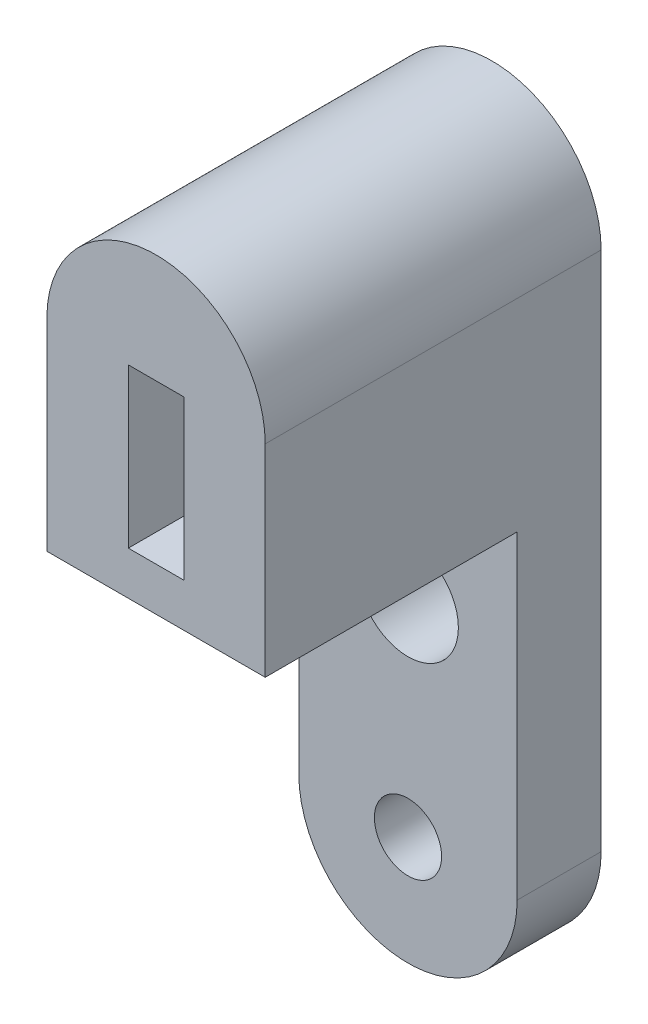
from build123d import *

# Parameters (mm, degrees)
SKETCH1_R           = 2
SKETCH1_R_2         = 3
SKETCH1_W           = 3.3
SKETCH1_H           = 9.45
BOSS_EXTRUDE1_DEPTH = 5
SKETCH1_4_W         = 3.3
SKETCH1_4_H         = 9.45
BOSS_EXTRUDE2_DEPTH = 20
CUT_EXTRUDE1_DEPTH  = 3.175
CUT_EXTRUDE2_REACH  = 35.989
SKETCH2_3_R         = 2.38125


with BuildPart() as part:
    # Sketch1 → Boss-Extrude1 (new body)
    with BuildSketch(Plane.XY):
        with BuildLine():
            ThreePointArc((-6.5, -17.71207008), (0, -24.21207008), (6.5, -17.71207008))
            Line((6.5, -17.71207008), (6.5, 13.31292992))
            ThreePointArc((6.5, 13.31292992), (0, 19.81292992), (-6.5, 13.31292992))
            Line((-6.5, 13.31292992), (-6.5, -17.71207008))
        make_face()
        with Locations((0, -17.71207008)):
            Circle(SKETCH1_R, mode=Mode.SUBTRACT)
        with Locations((0, -5.41207008)):
            Circle(SKETCH1_R_2, mode=Mode.SUBTRACT)
        with Locations((0, 8.58792992)):
            Rectangle(SKETCH1_W, SKETCH1_H, mode=Mode.SUBTRACT)
    extrude(amount=BOSS_EXTRUDE1_DEPTH)

    # Sketch1_4 → Boss-Extrude2 (add)
    with BuildSketch(Plane.XY):
        with BuildLine():
            Line((-6.5, 13.31292992), (-6.5, 1.276325687))
            Line((-6.5, 1.276325687), (6.5, 1.276325687))
            Line((6.5, 1.276325687), (6.5, 13.31292992))
            ThreePointArc((6.5, 13.31292992), (0, 19.81292992), (-6.5, 13.31292992))
        make_face()
        with Locations((0, 8.58792992)):
            Rectangle(SKETCH1_4_W, SKETCH1_4_H, mode=Mode.SUBTRACT)
    extrude(amount=BOSS_EXTRUDE2_DEPTH)

    # Sketch2 → Cut-Extrude1 (cut)
    with BuildSketch(Plane.ZY.offset(6.5)):
        Polygon((14.766026472, 8.58792992), (12.383013236, 12.71542992), (7.616986764, 12.71542992), (5.233973528, 8.58792992), (7.616986764, 4.46042992), (12.383013236, 4.46042992), align=None)
    extrude(amount=-CUT_EXTRUDE1_DEPTH, mode=Mode.SUBTRACT)

    # Sketch2_3 → Cut-Extrude2 (cut, up to next)
    with BuildSketch(Plane.ZY.offset(6.5), mode=Mode.PRIVATE) as cut_extrude2_sk1:
        with Locations((10, 8.58792992)):
            Circle(SKETCH2_3_R)
    cut_extrude2_tool1 = extrude(cut_extrude2_sk1.sketch, amount=-CUT_EXTRUDE2_REACH, mode=Mode.PRIVATE) & part.part
    add(cut_extrude2_tool1.solids().sort_by_distance((-6.5, 8.58793, 10))[0], mode=Mode.SUBTRACT)


solid = part.part
